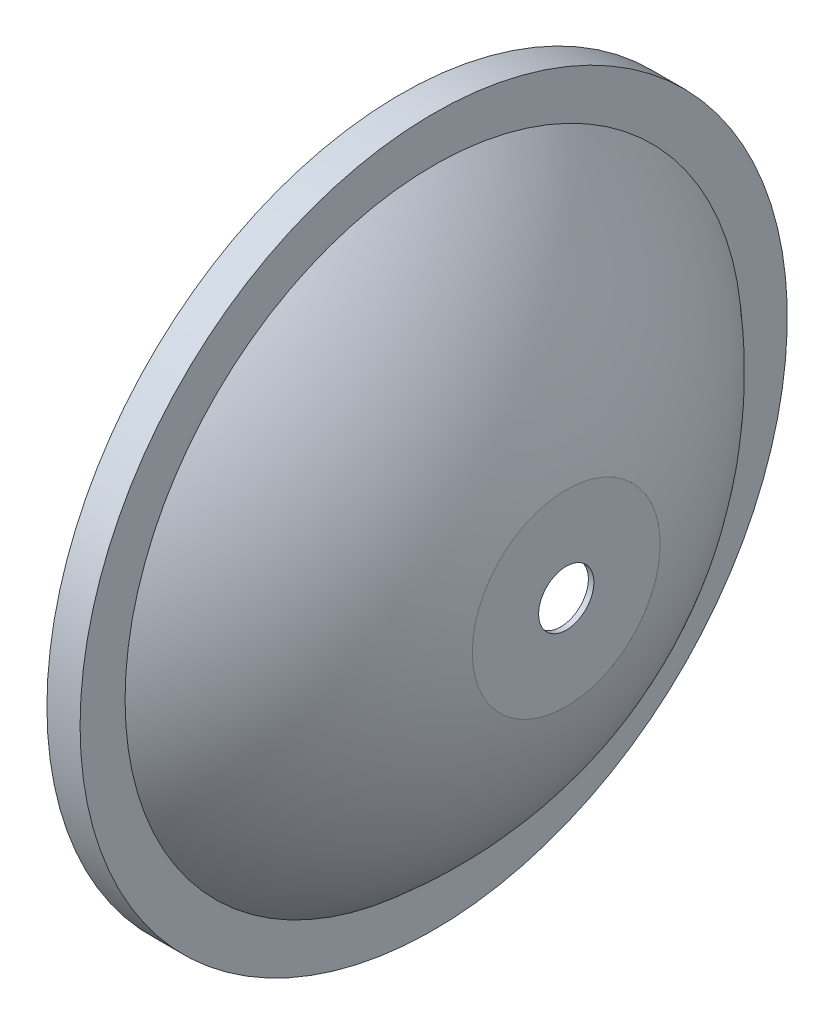
from build123d import *


with BuildPart() as part:
    # Sketch1 → Revolve1 (revolve)
    with BuildSketch(Plane.XY):
        with BuildLine():
            Line((41, 64), (47, 64))
            Line((47, 64), (47, 55.856960175))
            ThreePointArc((47, 55.856960175), (62.113205821, 38.352961589), (70.992957397, 17))
            Line((70.992957397, 17), (70.992957397, 5))
            Line((70.992957397, 5), (69.992957397, 5))
            Line((69.992957397, 5), (69.992957397, 16.881525843))
            ThreePointArc((69.992957397, 16.881525843), (61.108985686, 38.074819348), (46, 55.389529697))
            Line((46, 55.389529697), (46, 63))
            Line((46, 63), (41, 63))
            Line((41, 63), (41, 64))
        make_face()
    revolve(axis=Axis((0, 0, 0), (1, 0, 0)))


solid = part.part
